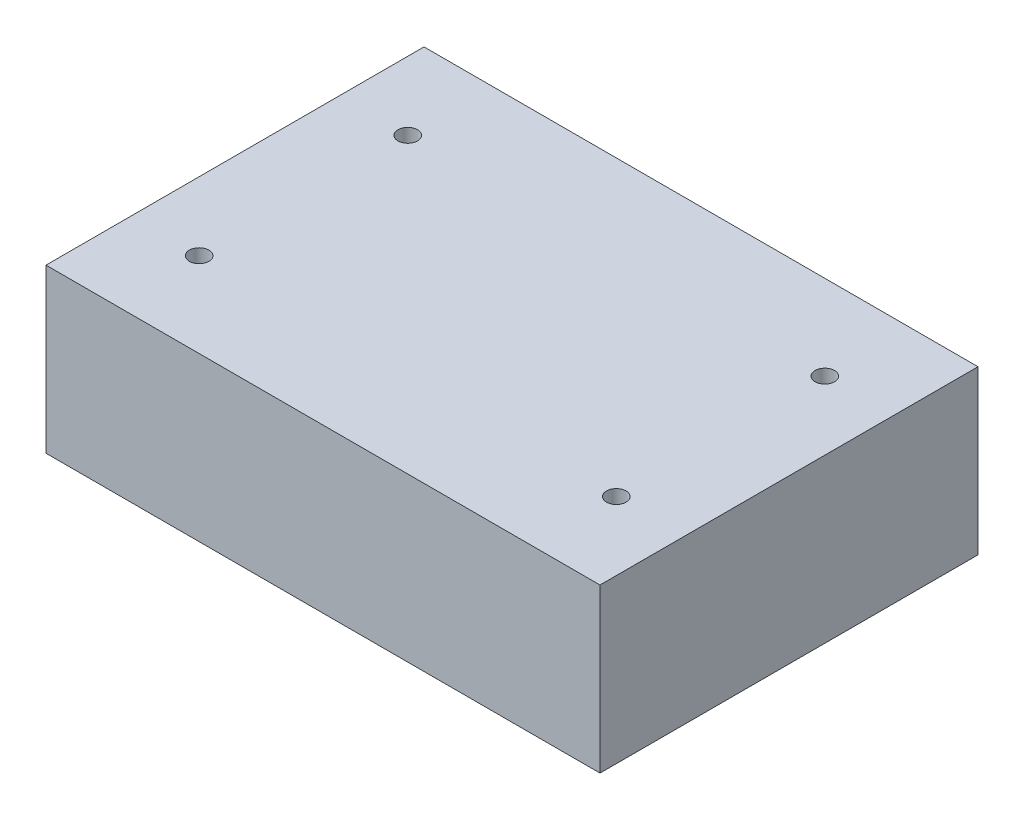
from build123d import *

# Parameters (mm, degrees)
SKETCH1_W           = 85
SKETCH1_H           = 58
SKETCH1_R           = 1.5
BOSS_EXTRUDE1_DEPTH = 25


with BuildPart() as part:
    # Sketch1 → Boss-Extrude1 (new body)
    with BuildSketch(Plane(origin=(0, 0, 0), x_dir=(1, 0, 0), z_dir=(0, 1, 0))):
        with Locations((42.5, 29)):
            Rectangle(SKETCH1_W, SKETCH1_H)
        with Locations((10.5, 45)):
            Circle(SKETCH1_R, mode=Mode.SUBTRACT)
        with Locations((74.5, 45)):
            Circle(SKETCH1_R, mode=Mode.SUBTRACT)
        with Locations((74.5, 13)):
            Circle(SKETCH1_R, mode=Mode.SUBTRACT)
        with Locations((10.5, 13)):
            Circle(SKETCH1_R, mode=Mode.SUBTRACT)
    extrude(amount=BOSS_EXTRUDE1_DEPTH)


solid = part.part
